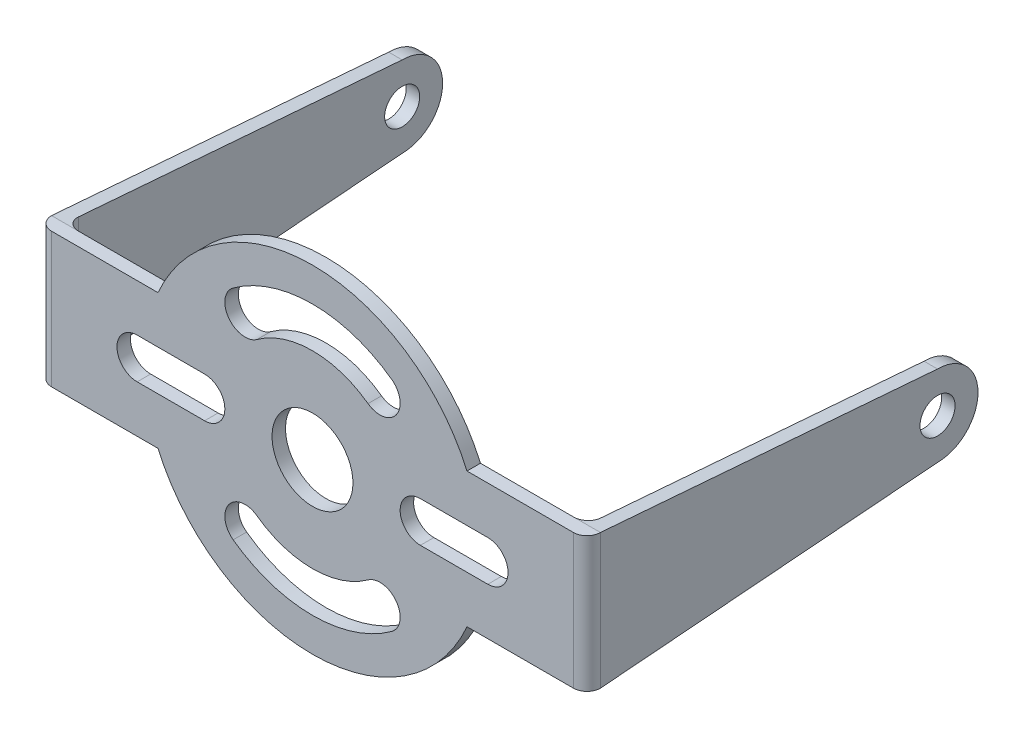
from build123d import *

# Parameters (mm, degrees)
SKETCH1_R           = 3
BOSS_EXTRUDE1_DEPTH = 1
SKETCH2_R           = 1.3
BOSS_EXTRUDE2_DEPTH = 1
FILLET1_R           = 1
CUT_EXTRUDE1_DEPTH  = 1


with BuildPart() as part:
    # Sketch1 → Boss-Extrude1 (new body)
    with BuildSketch(Plane.XY):
        with BuildLine():
            ThreePointArc((11.456439237, 5), (0, 12.5), (-11.456439237, 5))
            Line((-11.456439237, 5), (11.456439237, 5))
        make_face()
        with BuildLine():
            Line((11.456439237, 5), (-11.456439237, 5))
            ThreePointArc((-11.456439237, 5), (-12.5, 0), (-11.456439237, -5))
            Line((-11.456439237, -5), (11.456439237, -5))
            ThreePointArc((11.456439237, -5), (12.236328912, -2.553870546), (12.5, 0))
            ThreePointArc((12.5, 0), (12.236328912, 2.553870546), (11.456439237, 5))
        make_face()
        Circle(SKETCH1_R, mode=Mode.SUBTRACT)
        with BuildLine():
            Line((20.35, 5), (11.456439237, 5))
            ThreePointArc((11.456439237, 5), (12.236328912, 2.553870546), (12.5, 0))
            ThreePointArc((12.5, 0), (12.236328912, -2.553870546), (11.456439237, -5))
            Line((11.456439237, -5), (20.35, -5))
            Line((20.35, -5), (20.35, 5))
        make_face()
        with BuildLine():
            Line((-11.456439237, 5), (-20.35, 5))
            Line((-20.35, 5), (-20.35, -5))
            Line((-20.35, -5), (-11.456439237, -5))
            ThreePointArc((-11.456439237, -5), (-12.5, 0), (-11.456439237, 5))
        make_face()
        with BuildLine():
            Line((11.456439237, -5), (-11.456439237, -5))
            ThreePointArc((-11.456439237, -5), (0, -12.5), (11.456439237, -5))
        make_face()
    extrude(amount=BOSS_EXTRUDE1_DEPTH)

    # Sketch2 → Boss-Extrude2 (add)
    with BuildSketch(Plane.ZY.offset(20.35)):
        with BuildLine():
            Line((-25, -3), (0, -5))
            Line((0, -5), (0, 5))
            Line((0, 5), (-25, 3))
            ThreePointArc((-25, 3), (-28, 0), (-25, -3))
        make_face()
        with Locations((-25, 0)):
            Circle(SKETCH2_R, mode=Mode.SUBTRACT)
    boss_extrude2 = extrude(amount=-BOSS_EXTRUDE2_DEPTH)

    # Mirror1: Boss-Extrude2 across plane
    add(boss_extrude2.mirror(Plane.ZY))

    # Fillet1
    fillet1_edges = [part.edges().sort_by_distance(p)[0] for p in [
        (20.35, 0, 1),
        (-20.35, 0, 1),
        (19.35, 0, 0),
        (-19.35, 0, 0),
    ]]
    fillet(fillet1_edges, radius=FILLET1_R)

    # Sketch3 → Cut-Extrude1 (cut)
    with BuildSketch(Plane.XY.offset(1)):
        with BuildLine():
            ThreePointArc((8, 1.5), (6.5, 0), (8, -1.5))
            Line((8, -1.5), (13, -1.5))
            ThreePointArc((13, -1.5), (14.5, 0), (13, 1.5))
            Line((13, 1.5), (8, 1.5))
        make_face()
        with BuildLine():
            ThreePointArc((-4.117647107, 5.660828765), (-1.9e-08, 7), (4.117647076, 5.660828787))
            ThreePointArc((4.117647076, 5.660828787), (6.213034752, 5.991510614), (5.882352933, 8.086898291))
            ThreePointArc((5.882352933, 8.086898291), (6e-09, 10), (-5.882352923, 8.086898298))
            ThreePointArc((-5.882352923, 8.086898298), (-6.213034767, 5.991510634), (-4.117647107, 5.660828765))
        make_face()
        with BuildLine():
            ThreePointArc((4.117647035, -5.660828817), (-2.5e-08, -7), (-4.117647076, -5.660828787))
            ThreePointArc((-4.117647076, -5.660828787), (-6.213034774, -5.991510645), (-5.882352871, -8.086898336))
            ThreePointArc((-5.882352871, -8.086898336), (7.8e-08, -10), (5.882352997, -8.086898245))
            ThreePointArc((5.882352997, -8.086898245), (6.213034714, -5.991510562), (4.117647035, -5.660828817))
        make_face()
        with BuildLine():
            ThreePointArc((-8, -1.5), (-6.5, 0), (-8, 1.5))
            Line((-8, 1.5), (-13, 1.5))
            ThreePointArc((-13, 1.5), (-14.5, 0), (-13, -1.5))
            Line((-13, -1.5), (-8, -1.5))
        make_face()
    extrude(amount=-CUT_EXTRUDE1_DEPTH, mode=Mode.SUBTRACT)


solid = part.part
